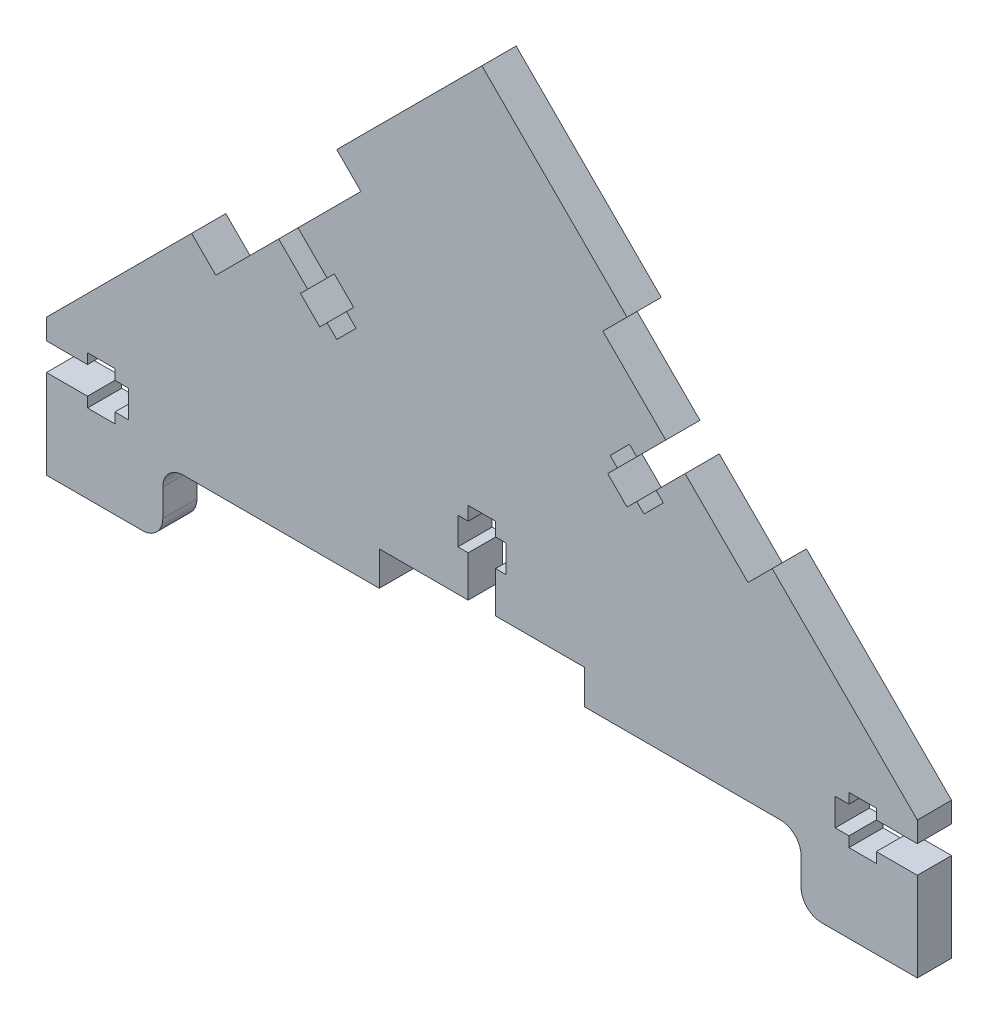
from build123d import *

# Parameters (mm, degrees)
BOSS_EXTRUDE1_DEPTH = 5
CUT_EXTRUDE1_DEPTH  = 10
SKETCH4_W           = 17
SKETCH4_H           = 10
BOSS_EXTRUDE3_DEPTH = 5
FILLET1_R           = 3


with BuildPart() as part:
    # Sketch1 → Boss-Extrude1 (new body)
    with BuildSketch(Plane.XY):
        Polygon((0, 0), (127.279220614, 0), (127.279220614, 10), (106.066017178, 31.213203436), (102.530483272, 27.67766953), (81.317279836, 48.890872965), (84.852813742, 52.426406871), (63.639610307, 73.639610307), (42.426406871, 52.426406871), (45.961940777, 48.890872965), (24.748737342, 27.67766953), (21.213203436, 31.213203436), (0, 10), align=None)
    extrude(amount=BOSS_EXTRUDE1_DEPTH)

    # Sketch2 → Cut-Extrude1 (cut)
    with BuildSketch(Plane.XY.offset(5)):
        Polygon((127.279220614, 3), (121.279220614, 3), (121.279220614, 1.5), (117.279220614, 1.5), (117.279220614, 3), (115.279220614, 3), (115.279220614, 7), (117.279220614, 7), (117.279220614, 8.5), (121.279220614, 8.5), (121.279220614, 7), (127.279220614, 7), align=None)
        Polygon((36.769552622, 39.69848481), (33.941125497, 36.870057685), (38.183766184, 32.627416998), (37.123106012, 31.566756826), (39.951533137, 28.738329701), (41.012193309, 29.798989873), (42.426406871, 28.384776311), (45.254833996, 31.213203436), (43.840620434, 32.627416998), (44.901280605, 33.68807717), (42.072853481, 36.516504294), (41.012193309, 35.455844123), align=None)
        Polygon((0, 7), (0, 3), (6, 3), (6, 1.5), (10, 1.5), (10, 3), (12, 3), (12, 7), (10, 7), (10, 8.5), (6, 8.5), (6, 7), align=None)
        Polygon((48.639610307, 5), (61.639610307, 5), (61.639610307, 11), (60.139610307, 11), (60.139610307, 15), (61.639610307, 15), (61.639610307, 17), (65.639610307, 17), (65.639610307, 15), (67.139610307, 15), (67.139610307, 11), (65.639610307, 11), (65.639610307, 5), (78.639610307, 5), (78.639610307, 0), (48.639610307, 0), align=None)
        Polygon((93.338095117, 36.870057685), (89.09545443, 32.627416998), (90.156114601, 31.566756826), (87.327687477, 28.738329701), (86.267027305, 29.798989873), (84.852813742, 28.384776311), (82.024386618, 31.213203436), (83.43860018, 32.627416998), (82.377940008, 33.68807717), (85.206367133, 36.516504294), (86.267027305, 35.455844123), (90.509667992, 39.69848481), align=None)
    extrude(amount=-CUT_EXTRUDE1_DEPTH, mode=Mode.SUBTRACT)

    # Sketch4 → Boss-Extrude3 (add)
    with BuildSketch(Plane.XY.offset(5)):
        with Locations((8.5, -5)):
            Rectangle(SKETCH4_W, SKETCH4_H)
        with Locations((118.779220614, -5)):
            Rectangle(SKETCH4_W, SKETCH4_H)
    extrude(amount=-BOSS_EXTRUDE3_DEPTH)

    # Fillet1
    fillet1_edges = [part.edges().sort_by_distance(p)[0] for p in [
        (17, 0, 2.5),
        (17, -10, 2.5),
        (110.279220614, -10, 2.5),
        (110.279220614, 0, 2.5),
    ]]
    fillet(fillet1_edges, radius=FILLET1_R)


solid = part.part
